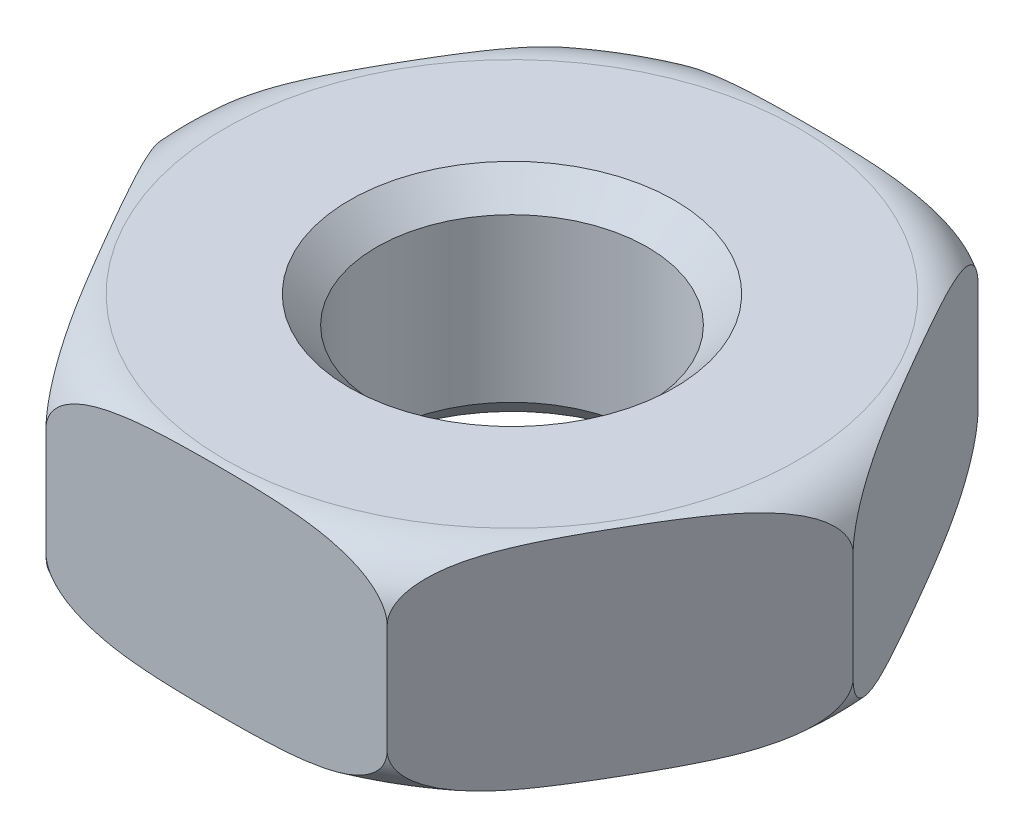
from build123d import *

# Parameters (mm, degrees)
SKETCH1_R           = 1.25
BOSS_EXTRUDE1_DEPTH = 1
CHAMFER1_SIZE       = 0.25


with BuildPart() as part:
    # Sketch1 → Boss-Extrude1 (new body, symmetric)
    with BuildSketch(Plane(origin=(0, 0, 0), x_dir=(1, 0, 0), z_dir=(0, 1, 0))):
        Polygon((-1.575, 2.727980022), (-3.15, 0), (-1.575, -2.727980022), (1.575, -2.727980022), (3.15, 0), (1.575, 2.727980022), align=None)
        Circle(SKETCH1_R, mode=Mode.SUBTRACT)
    extrude(amount=BOSS_EXTRUDE1_DEPTH, both=True)

    # Chamfer1
    chamfer1_edges = [part.edges().sort_by_distance(p)[0] for p in [
        (-1.25, -1, 0),
        (-1.25, 1, 0),
    ]]
    chamfer(chamfer1_edges, length=CHAMFER1_SIZE)

    # Sketch3 → Cut-Revolve1 (revolve, cut)
    with BuildSketch(Plane.XY):
        with BuildLine():
            Line((2.65, 1), (3.15, 1))
            Line((3.15, 1), (3.15, 0.5))
            ThreePointArc((3.15, 0.5), (3.003553391, 0.853553391), (2.65, 1))
        make_face()
    cut_revolve1 = revolve(axis=Axis((0, 1, 0), (0, -1, 0)), mode=Mode.SUBTRACT)

    # Mirror1: Cut-Revolve1 across plane
    add(cut_revolve1.mirror(Plane.ZX), mode=Mode.SUBTRACT)


solid = part.part
